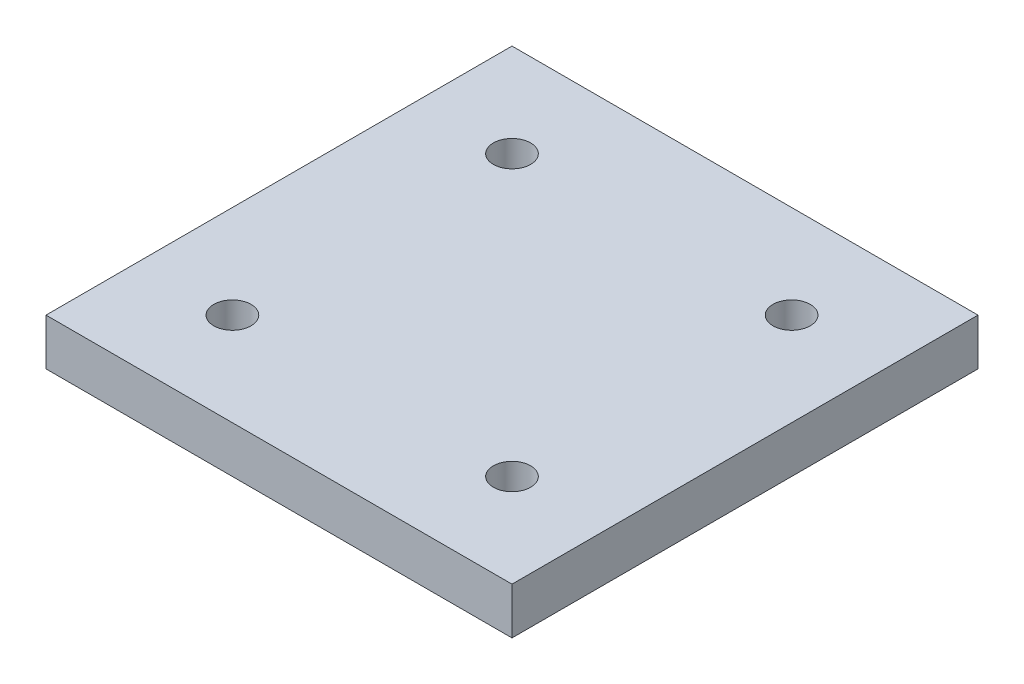
from build123d import *

# Parameters (mm, degrees)
SKETCH_1_W          = 100
SKETCH_1_H          = 100
EXTRUDE_1_DEPTH     = 10
SKETCH_2_R          = 4
CUT_EXTRUDE_1_DEPTH = 11


with BuildPart() as part:
    # Эскиз1 → Бобышка-Вытянуть1 (new body)
    with BuildSketch(Plane(origin=(0, 0, 0), x_dir=(1, 0, 0), z_dir=(0, 1, 0))):
        Rectangle(SKETCH_1_W, SKETCH_1_H)
    extrude(amount=EXTRUDE_1_DEPTH)

    # Эскиз2 → Вырез-Вытянуть1 (cut, through all)
    with BuildSketch(Plane(origin=(0, 10, 0), x_dir=(1, 0, 0), z_dir=(0, 1, 0))):
        with Locations((-30, 30)):
            Circle(SKETCH_2_R)
        with Locations((30, 30)):
            Circle(SKETCH_2_R)
        with Locations((-30, -30)):
            Circle(SKETCH_2_R)
        with Locations((30, -30)):
            Circle(SKETCH_2_R)
    extrude(amount=-CUT_EXTRUDE_1_DEPTH, mode=Mode.SUBTRACT)


solid = part.part
